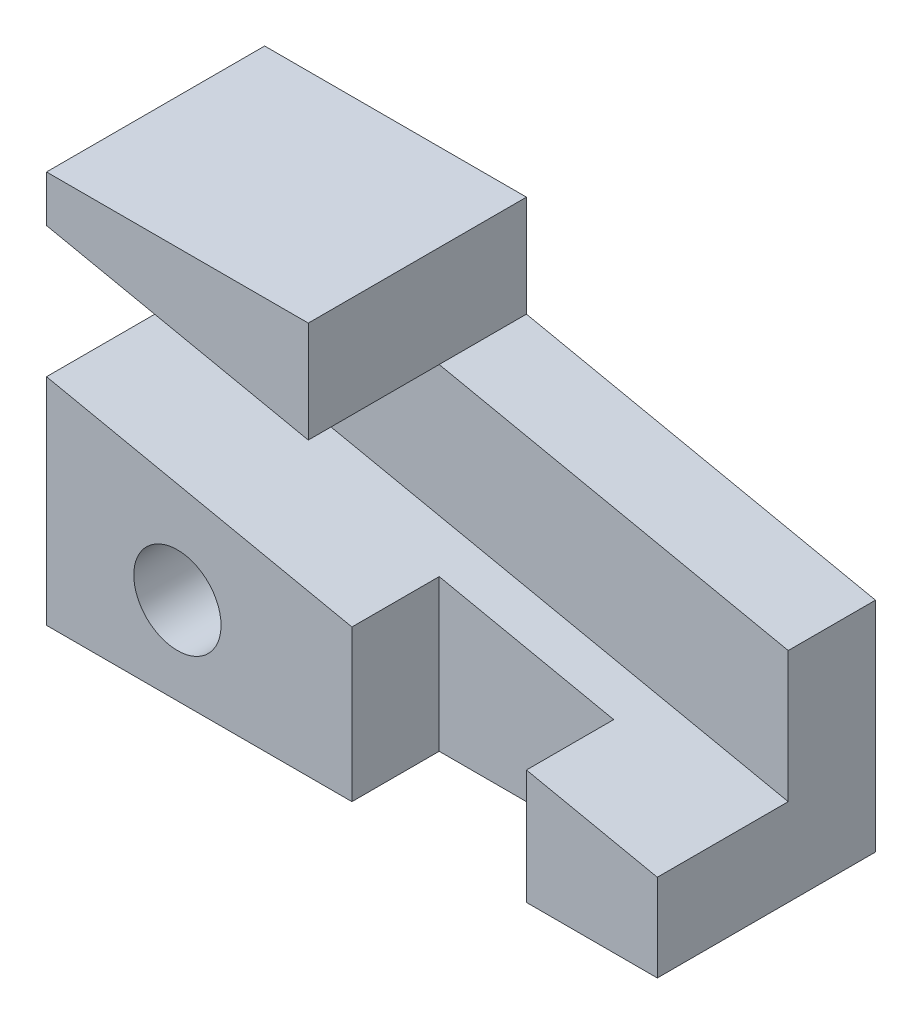
from build123d import *

# Parameters (mm, degrees)
SKETCH1_W           = 70
SKETCH1_H           = 25
BOSS_EXTRUDE1_DEPTH = 45
CUT_EXTRUDE1_DEPTH  = 15
CUT_EXTRUDE2_DEPTH  = 26
SKETCH4_W           = 20
SKETCH4_H           = 10
CUT_EXTRUDE3_DEPTH  = 46
SKETCH5_R           = 5
CUT_EXTRUDE4_DEPTH  = 26


with BuildPart() as part:
    # Sketch1 → Boss-Extrude1 (new body)
    with BuildSketch(Plane(origin=(0, 0, 0), x_dir=(1, 0, 0), z_dir=(0, 1, 0))):
        with Locations((35, 12.5)):
            Rectangle(SKETCH1_W, SKETCH1_H)
    extrude(amount=BOSS_EXTRUDE1_DEPTH)

    # Sketch2 → Cut-Extrude1 (cut)
    with BuildSketch(Plane.XY):
        Polygon((0, 39.67789539), (0, 24.67789539), (70, 10), (70, 25), align=None)
    extrude(amount=-CUT_EXTRUDE1_DEPTH, mode=Mode.SUBTRACT)

    # Sketch3 → Cut-Extrude2 (cut, through all)
    with BuildSketch(Plane.XY):
        Polygon((30, 45), (30, 33.387368794), (70, 25), (70, 45), align=None)
    extrude(amount=-CUT_EXTRUDE2_DEPTH, mode=Mode.SUBTRACT)

    # Sketch4 → Cut-Extrude3 (cut, through all)
    with BuildSketch(Plane(origin=(0, 0, 0), x_dir=(-1, 0, 0), z_dir=(0, -1, 0))):
        with Locations((-45, 5)):
            Rectangle(SKETCH4_W, SKETCH4_H)
    extrude(amount=-CUT_EXTRUDE3_DEPTH, mode=Mode.SUBTRACT)

    # Sketch5 → Cut-Extrude4 (cut, through all)
    with BuildSketch(Plane.XY):
        with Locations((15, 10)):
            Circle(SKETCH5_R)
    extrude(amount=-CUT_EXTRUDE4_DEPTH, mode=Mode.SUBTRACT)


solid = part.part
